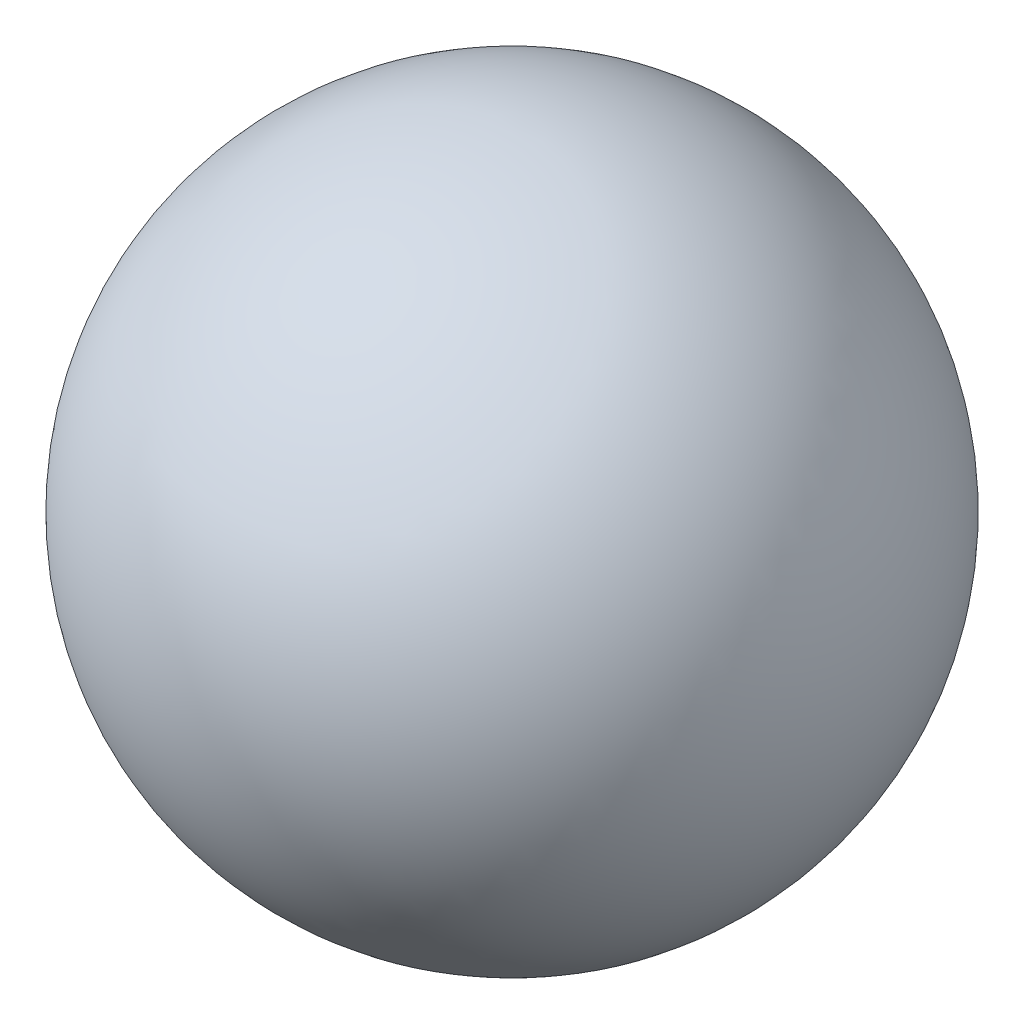
from build123d import *


with BuildPart() as part:
    # Sketch1 → Revolve1 (revolve)
    with BuildSketch(Plane.XY):
        with BuildLine():
            Line((0, 80), (0, 76))
            Line((0, 76), (0, -76))
            Line((0, -76), (0, -80))
            ThreePointArc((0, -80), (-80, 0), (0, 80))
        make_face()
    revolve(axis=Axis((0, 105.084210526, 0), (0, -1, 0)))


solid = part.part
